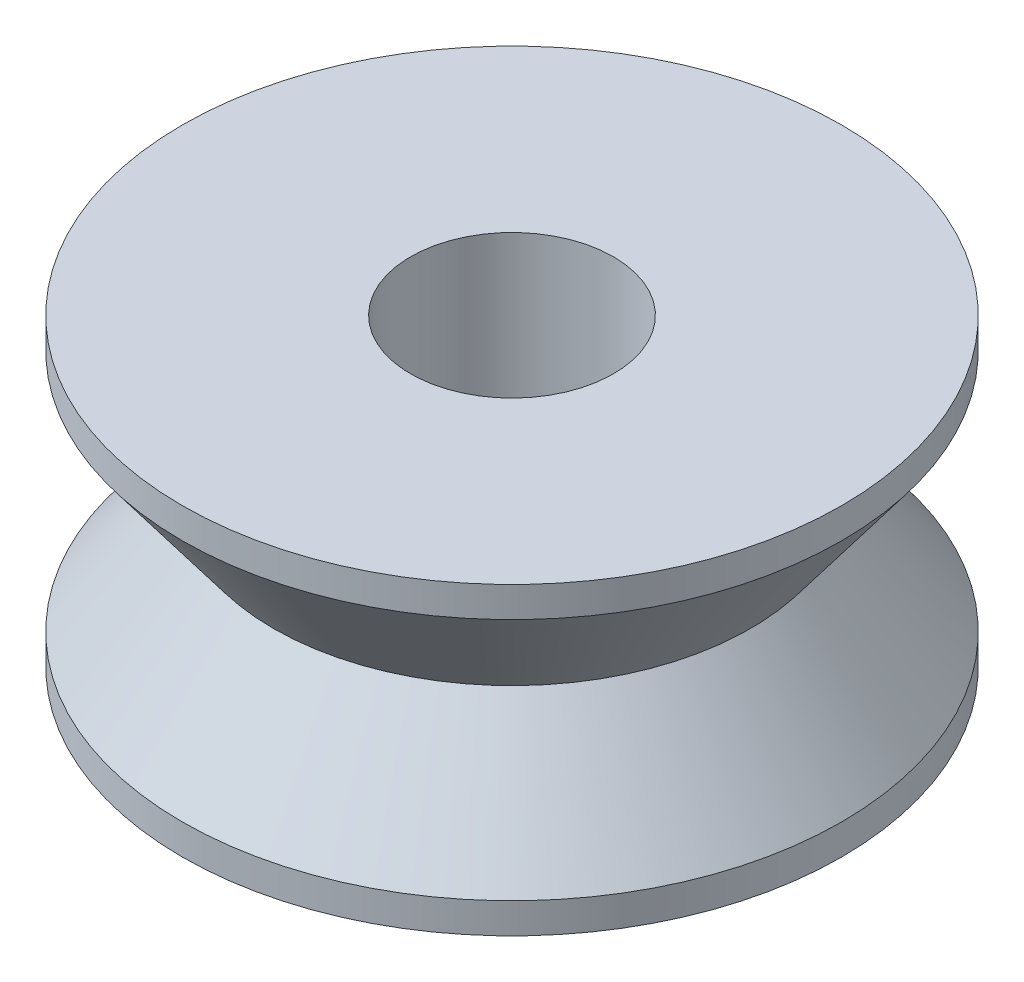
from build123d import *


with BuildPart() as part:
    # Sketch1 → Revolve1 (revolve)
    with BuildSketch(Plane.XY):
        Polygon((-6.5, 3), (-6.5, 2.4), (-4.7, 0), (-6.5, -2.4), (-6.5, -3), (-2, -3), (-2, 3), align=None)
    revolve(axis=Axis((0, 0, 0), (0, 1, 0)))


solid = part.part
